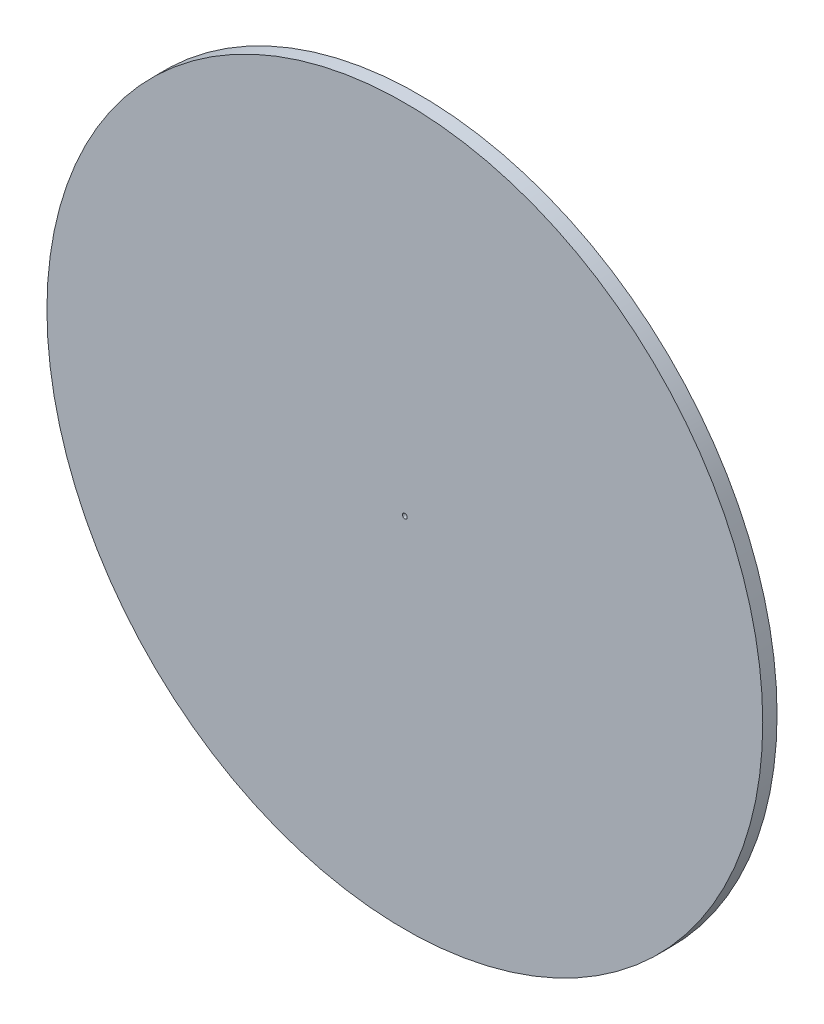
from build123d import *

# Parameters (mm, degrees)
CROQUIS1_R              = 75
CROQUIS1_R_2            = 0.5
SALIENTE_EXTRUIR1_DEPTH = 3


with BuildPart() as part:
    # Croquis1 → Saliente-Extruir1 (new body)
    with BuildSketch(Plane.XY):
        Circle(CROQUIS1_R)
        Circle(CROQUIS1_R_2, mode=Mode.SUBTRACT)
    extrude(amount=SALIENTE_EXTRUIR1_DEPTH)


solid = part.part
